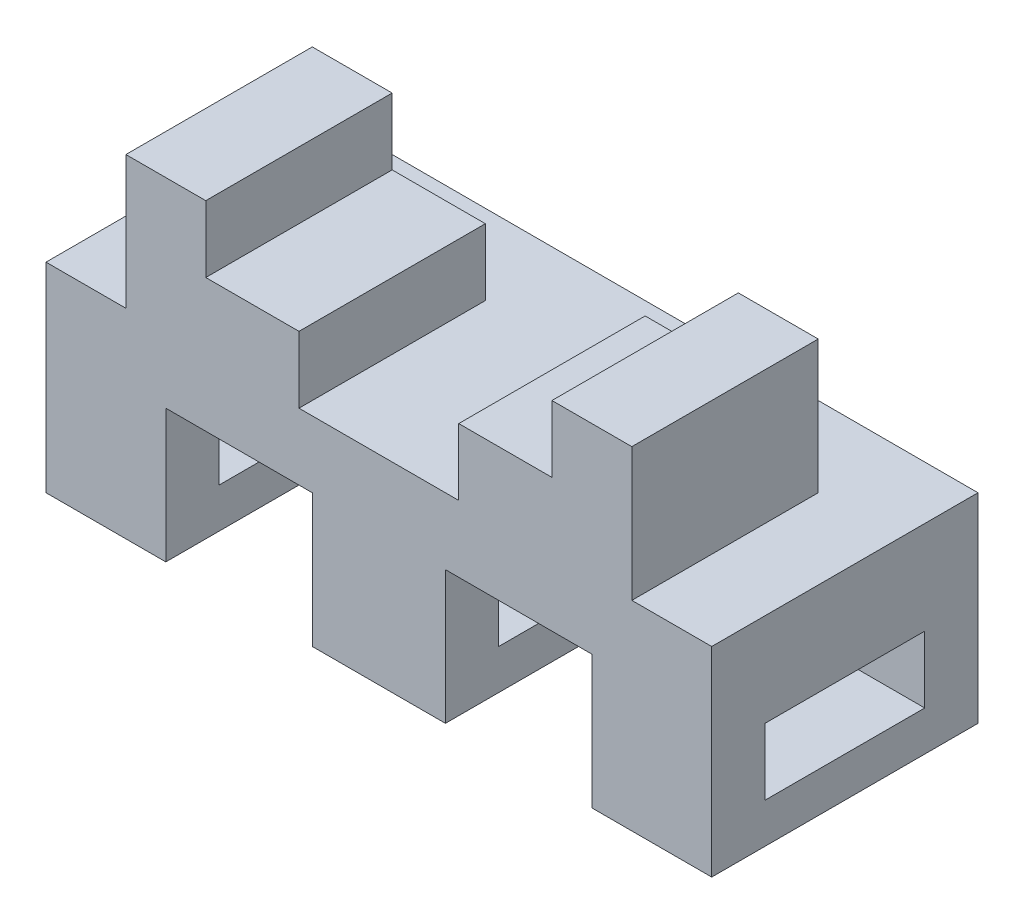
from build123d import *

# Parameters (mm, degrees)
SKETCH2_W               = 127
SKETCH2_H               = 50.8
BOSS_EXTRUDE1_DEPTH     = 38.1
SKETCH4_W               = 27.94
SKETCH4_H               = 25.4
CUT_EXTRUDE1_DEPTH      = 26.4
CUT_EXTRUDE1_DEPTH_BACK = 26.4
SKETCH5_W               = 30.48
SKETCH5_H               = 12.7
CUT_EXTRUDE2_DEPTH      = 64.5
CUT_EXTRUDE2_DEPTH_BACK = 64.5
BOSS_EXTRUDE2_START     = -50.8
BOSS_EXTRUDE2_DEPTH     = 35.56


with BuildPart() as part:
    # Sketch2 → Boss-Extrude1 (new body)
    with BuildSketch(Plane(origin=(0, 0, 0), x_dir=(1, 0, 0), z_dir=(0, 1, 0))):
        Rectangle(SKETCH2_W, SKETCH2_H)
    extrude(amount=BOSS_EXTRUDE1_DEPTH)

    # Sketch4 → Cut-Extrude1 (cut, two sides)
    with BuildSketch(Plane.XY) as cut_extrude1_sk:
        with Locations((-26.67, 12.7)):
            Rectangle(SKETCH4_W, SKETCH4_H)
        with Locations((26.67, 12.7)):
            Rectangle(SKETCH4_W, SKETCH4_H)
    extrude(amount=CUT_EXTRUDE1_DEPTH, mode=Mode.SUBTRACT)
    extrude(cut_extrude1_sk.sketch, amount=-CUT_EXTRUDE1_DEPTH_BACK, mode=Mode.SUBTRACT)

    # Sketch5 → Cut-Extrude2 (cut, two sides)
    with BuildSketch(Plane(origin=(0, 0, 0), x_dir=(0, 0, -1), z_dir=(1, 0, 0))) as cut_extrude2_sk:
        with Locations((0, 13.97)):
            Rectangle(SKETCH5_W, SKETCH5_H)
    extrude(amount=CUT_EXTRUDE2_DEPTH, mode=Mode.SUBTRACT)
    extrude(cut_extrude2_sk.sketch, amount=-CUT_EXTRUDE2_DEPTH_BACK, mode=Mode.SUBTRACT)

    # Sketch7 → Boss-Extrude2 (add)
    with BuildSketch(Plane(origin=(0, 0, -25.4), x_dir=(-1, 0, 0), z_dir=(0, 0, -1)).offset(BOSS_EXTRUDE2_START)):
        Polygon((48.26, 38.1), (48.26, 63.5), (33.02, 63.5), (33.02, 50.8), (15.24, 50.8), (15.24, 38.1), align=None)
        Polygon((-15.24, 38.1), (-48.26, 38.1), (-48.26, 63.5), (-33.02, 63.5), (-33.02, 50.8), (-15.24, 50.8), align=None)
    extrude(amount=BOSS_EXTRUDE2_DEPTH)


solid = part.part
